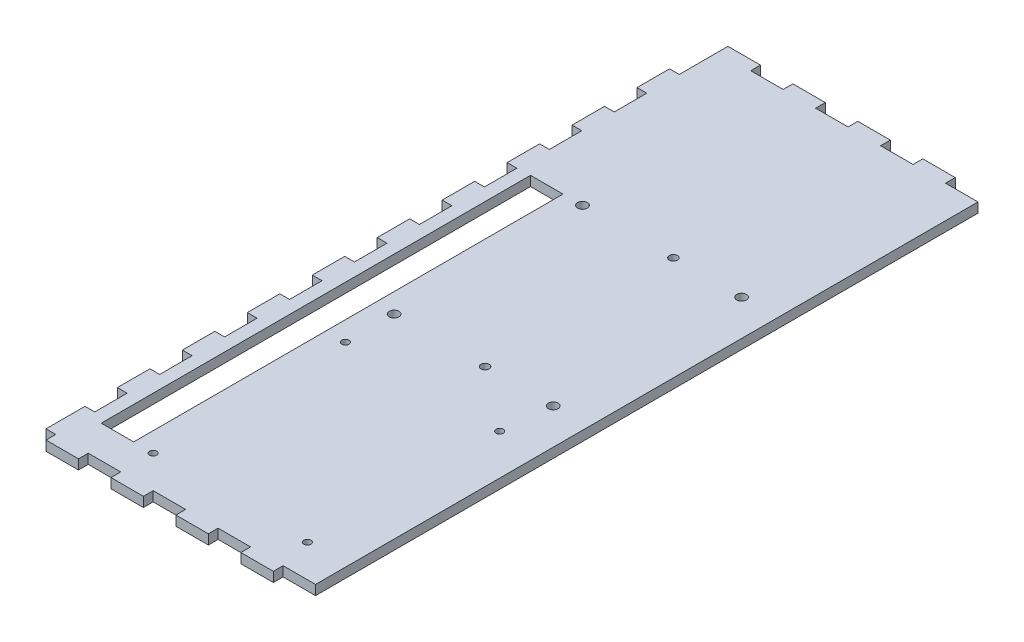
from build123d import *

# Parameters (mm, degrees)
SKETCH1_W           = 80
SKETCH1_H           = 204
BOSS_EXTRUDE1_DEPTH = 3
SKETCH2_W           = 10
SKETCH2_H           = 3
BOSS_EXTRUDE2_DEPTH = 3
LPATTERN1_COUNT     = 4
LPATTERN1_PITCH     = 20
SKETCH3_W           = 10
SKETCH3_H           = 3
BOSS_EXTRUDE3_DEPTH = 3
LPATTERN2_COUNT     = 4
LPATTERN2_PITCH     = 20
SKETCH4_R           = 1.1
SKETCH4_R_2         = 1.5
SKETCH4_R_3         = 1.25
SKETCH4_W           = 10
SKETCH4_H           = 132.2
CUT_EXTRUDE1_DEPTH  = 4
SKETCH5_W           = 12
SKETCH5_H           = 3
SKETCH5_W_2         = 10
BOSS_EXTRUDE4_DEPTH = 3


with BuildPart() as part:
    # Sketch1 → Boss-Extrude1 (new body)
    with BuildSketch(Plane(origin=(0, 0, 0), x_dir=(1, 0, 0), z_dir=(0, 1, 0))):
        with Locations((40, 102)):
            Rectangle(SKETCH1_W, SKETCH1_H)
    extrude(amount=BOSS_EXTRUDE1_DEPTH)

    # Sketch2 → Boss-Extrude2 (add)
    with BuildSketch(Plane.XY):
        with Locations((5, 1.5)):
            Rectangle(SKETCH2_W, SKETCH2_H)
    boss_extrude2 = extrude(amount=BOSS_EXTRUDE2_DEPTH)

    # LPattern1: Boss-Extrude2 ×4
    with Locations(*[(i * LPATTERN1_PITCH, 0, 0) for i in range(1, LPATTERN1_COUNT)]):
        add(boss_extrude2)

    # Sketch3 → Boss-Extrude3 (add)
    with BuildSketch(Plane(origin=(0, 0, -204), x_dir=(-1, 0, 0), z_dir=(0, 0, -1))):
        with Locations((-5, 1.5)):
            Rectangle(SKETCH3_W, SKETCH3_H)
    boss_extrude3 = extrude(amount=BOSS_EXTRUDE3_DEPTH)

    # LPattern2: Boss-Extrude3 ×4
    with Locations(*[(i * LPATTERN2_PITCH, 0, 0) for i in range(1, LPATTERN2_COUNT)]):
        add(boss_extrude3)

    # Sketch4 → Cut-Extrude1 (cut, through all)
    with BuildSketch(Plane(origin=(0, 3, 0), x_dir=(1, 0, 0), z_dir=(0, 1, 0))):
        with Locations((20, 10)):
            Circle(SKETCH4_R)
        with Locations((67.5, 10)):
            Circle(SKETCH4_R)
        with Locations((20, 69.2)):
            Circle(SKETCH4_R)
        with Locations((67.5, 69.2)):
            Circle(SKETCH4_R)
        with Locations((20, 84.2)):
            Circle(SKETCH4_R_2)
        with Locations((69, 84.2)):
            Circle(SKETCH4_R_2)
        with Locations((69, 142.2)):
            Circle(SKETCH4_R_2)
        with Locations((20, 142.2)):
            Circle(SKETCH4_R_2)
        with Locations((48, 84.2)):
            Circle(SKETCH4_R_3)
        with Locations((48, 142.2)):
            Circle(SKETCH4_R_3)
        with Locations((9, 76.1)):
            Rectangle(SKETCH4_W, SKETCH4_H)
    extrude(amount=-CUT_EXTRUDE1_DEPTH, mode=Mode.SUBTRACT)

    # Sketch5 → Boss-Extrude4 (add)
    with BuildSketch(Plane.ZY):
        with Locations((-6, 1.5)):
            Rectangle(SKETCH5_W, SKETCH5_H)
        with Locations((-27, 1.5)):
            Rectangle(SKETCH5_W_2, SKETCH5_H)
        with Locations((-47, 1.5)):
            Rectangle(SKETCH5_W_2, SKETCH5_H)
        with Locations((-67, 1.5)):
            Rectangle(SKETCH5_W_2, SKETCH5_H)
        with Locations((-87, 1.5)):
            Rectangle(SKETCH5_W_2, SKETCH5_H)
        with Locations((-107, 1.5)):
            Rectangle(SKETCH5_W_2, SKETCH5_H)
        with Locations((-127, 1.5)):
            Rectangle(SKETCH5_W_2, SKETCH5_H)
        with Locations((-147, 1.5)):
            Rectangle(SKETCH5_W_2, SKETCH5_H)
        with Locations((-167, 1.5)):
            Rectangle(SKETCH5_W_2, SKETCH5_H)
        with Locations((-187, 1.5)):
            Rectangle(SKETCH5_W_2, SKETCH5_H)
    extrude(amount=BOSS_EXTRUDE4_DEPTH)


solid = part.part
